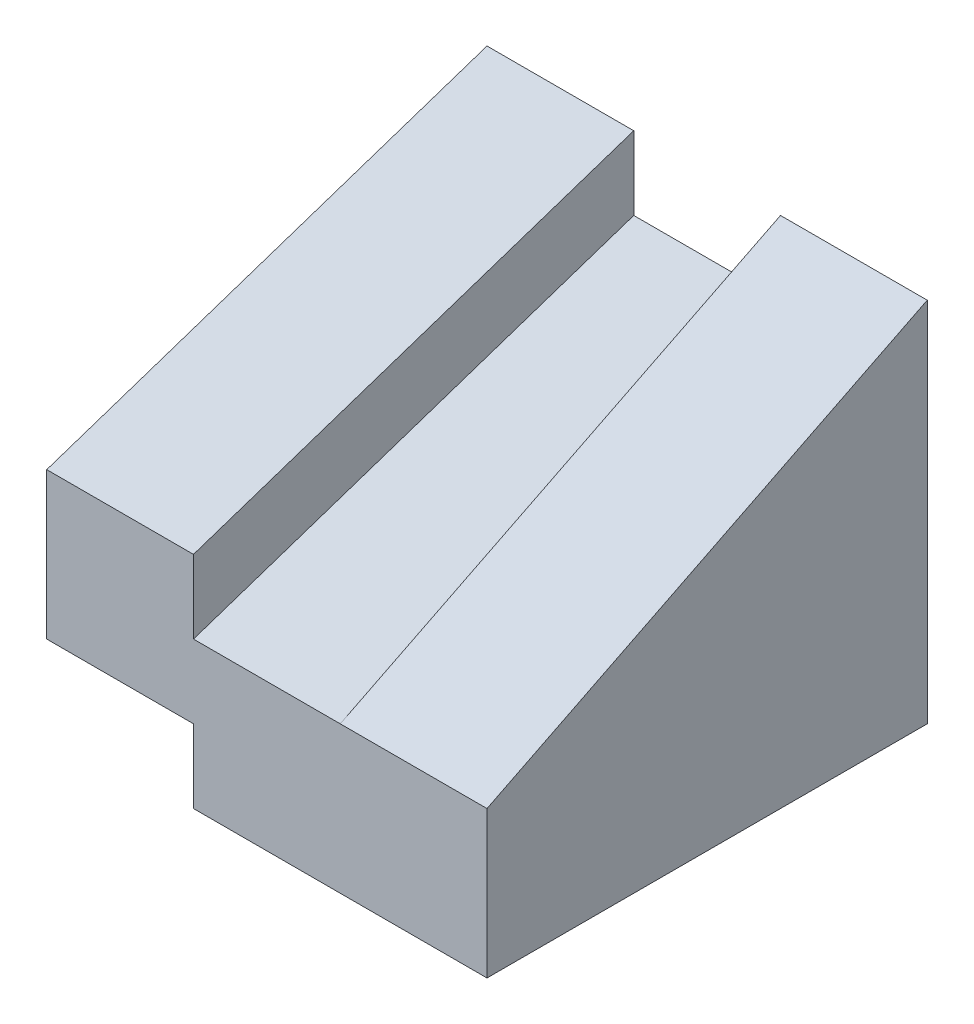
from build123d import *

# Parameters (mm, degrees)
SKETCH1_W           = 6
SKETCH1_H           = 6
BOSS_EXTRUDE1_DEPTH = 5
SKETCH2_W           = 6
SKETCH2_H           = 1
CUT_EXTRUDE1_DEPTH  = 2
CUT_EXTRUDE2_DEPTH  = 2
CUT_EXTRUDE3_DEPTH  = 2


with BuildPart() as part:
    # Sketch1 → Boss-Extrude1 (new body)
    with BuildSketch(Plane(origin=(0, 0, 0), x_dir=(1, 0, 0), z_dir=(0, 1, 0))):
        Rectangle(SKETCH1_W, SKETCH1_H)
    extrude(amount=BOSS_EXTRUDE1_DEPTH)

    # Sketch2 → Cut-Extrude1 (cut)
    with BuildSketch(Plane.ZY.offset(3)):
        Polygon((3, 5), (-3, 5), (3, 3), align=None)
        with Locations((0, 0.5)):
            Rectangle(SKETCH2_W, SKETCH2_H)
    extrude(amount=-CUT_EXTRUDE1_DEPTH, mode=Mode.SUBTRACT)

    # Sketch3 → Cut-Extrude2 (cut)
    with BuildSketch(Plane.ZY.offset(1)):
        Polygon((-3, 5), (-3, 4), (3, 2), (3, 3), align=None)
        Polygon((3, 3), (3, 5), (-3, 5), align=None)
    extrude(amount=-CUT_EXTRUDE2_DEPTH, mode=Mode.SUBTRACT)

    # Sketch4 → Cut-Extrude3 (cut)
    with BuildSketch(Plane.ZY.offset(-1)):
        Polygon((-3, 5), (3, 2), (3, 5), align=None)
    extrude(amount=-CUT_EXTRUDE3_DEPTH, mode=Mode.SUBTRACT)


solid = part.part
